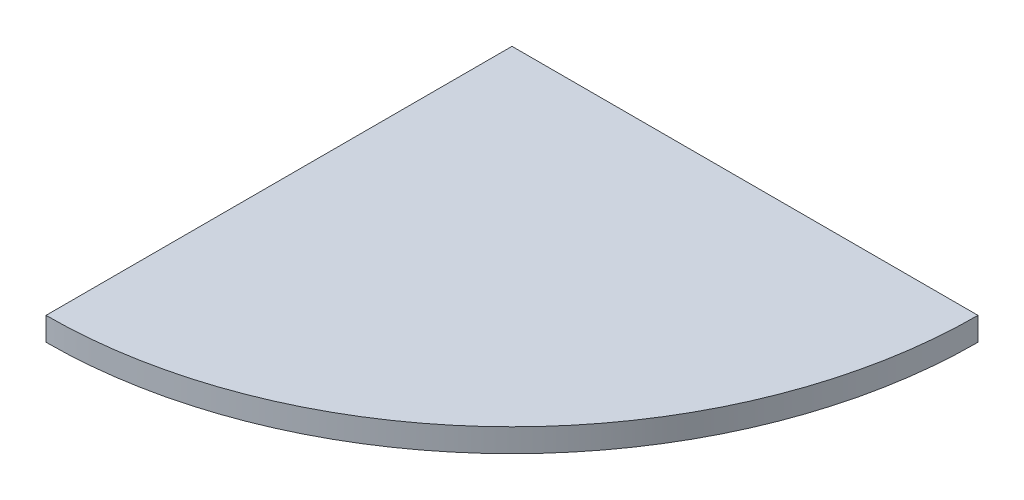
from build123d import *

# Parameters (mm, degrees)
BOSS_EXTRUDE1_DEPTH = 15.24


with BuildPart() as part:
    # Sketch1 → Boss-Extrude1 (new body, symmetric)
    with BuildSketch(Plane(origin=(0, 0, 0), x_dir=(1, 0, 0), z_dir=(0, 1, 0))):
        with BuildLine():
            Line((0, 0), (609.6, 0))
            ThreePointArc((609.6, 0), (431.052293811, -431.052293811), (0, -609.6))
            Line((0, -609.6), (0, 0))
        make_face()
    extrude(amount=BOSS_EXTRUDE1_DEPTH, both=True)


solid = part.part
